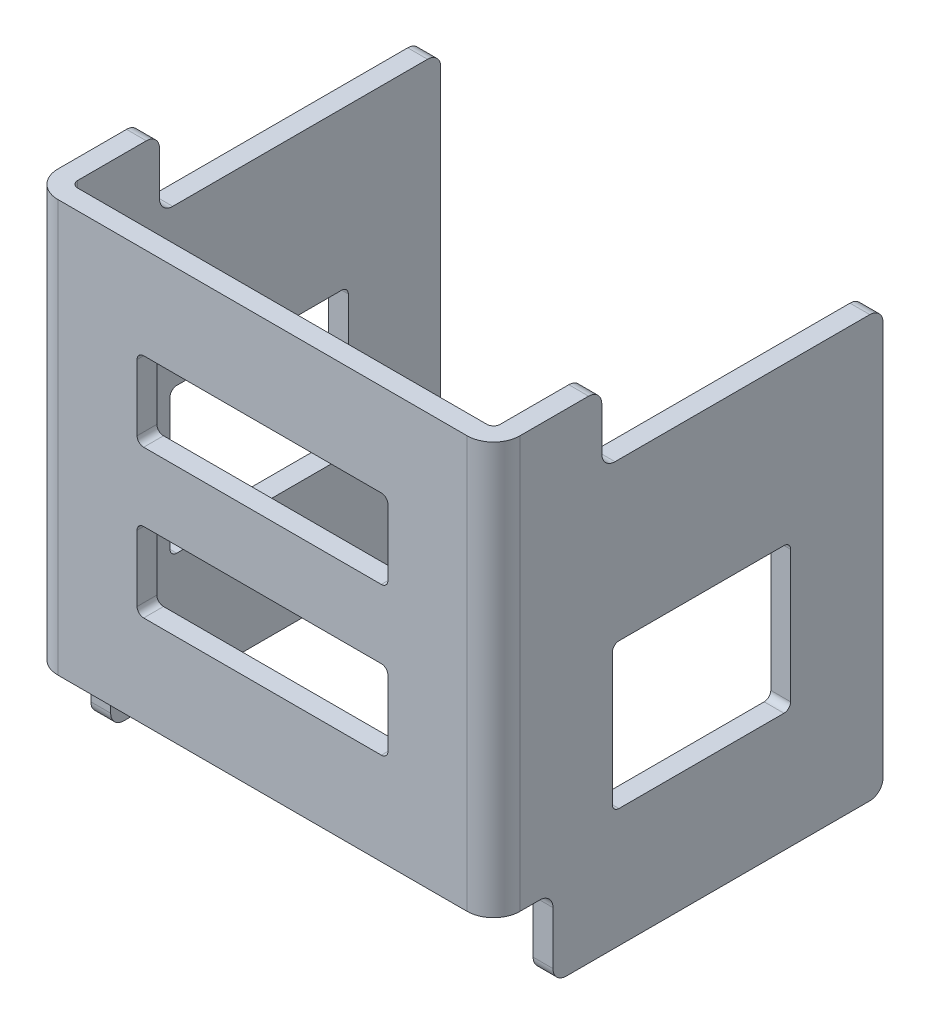
from build123d import *

# Parameters (mm, degrees)
SKETCH1_W           = 37.2
SKETCH1_H           = 29.5
BOSS_EXTRUDE1_DEPTH = 1.5
SKETCH2_W           = 4.5
SKETCH2_H           = 6
CUT_EXTRUDE1_DEPTH  = 2.5
SKETCH3_W           = 1.5
SKETCH3_H           = 31.2
BOSS_EXTRUDE2_DEPTH = 33.5
SKETCH4_W           = 1.5
SKETCH4_H           = 31.2
BOSS_EXTRUDE3_DEPTH = 28
SKETCH5_W           = 1.5
SKETCH5_H           = 25
BOSS_EXTRUDE4_DEPTH = 6
CUT_EXTRUDE2_REACH  = 37
SKETCH6_W           = 21.3
SKETCH6_H           = 5.3
SKETCH7_W           = 21.3
SKETCH7_H           = 5.3
CUT_EXTRUDE3_DEPTH  = 36
FILLET1_R           = 0.5
FILLET2_R           = 2
SKETCH8_W           = 19
SKETCH8_H           = 6
CUT_EXTRUDE4_DEPTH  = 1.5
FILLET3_R           = 0.5
SKETCH9_W           = 13.5
SKETCH9_H           = 11
CUT_EXTRUDE5_DEPTH  = 35
FILLET4_R           = 0.5
FILLET5_R           = 1


with BuildPart() as part:
    # Sketch1 → Boss-Extrude1 (new body)
    with BuildSketch(Plane(origin=(16, 0, 0), x_dir=(0, -1, 0), z_dir=(-1, 0, 0))):
        with Locations((46.1, 3.75)):
            Rectangle(SKETCH1_W, SKETCH1_H)
    extrude(amount=-BOSS_EXTRUDE1_DEPTH)

    # Sketch2 → Cut-Extrude1 (cut, through all)
    with BuildSketch(Plane(origin=(17.5, 0, 0), x_dir=(0, 0, -1), z_dir=(1, 0, 0))):
        with Locations((-16.25, -61.7)):
            Rectangle(SKETCH2_W, SKETCH2_H)
    extrude(amount=-CUT_EXTRUDE1_DEPTH, mode=Mode.SUBTRACT)

    # Sketch3 → Boss-Extrude2 (add)
    with BuildSketch(Plane.ZY.offset(-16)):
        with Locations((17.75, -43.1)):
            Rectangle(SKETCH3_W, SKETCH3_H)
    extrude(amount=BOSS_EXTRUDE2_DEPTH)

    # Sketch4 → Boss-Extrude3 (add)
    with BuildSketch(Plane(origin=(0, 0, 17), x_dir=(-1, 0, 0), z_dir=(0, 0, -1))):
        with Locations((16.75, -43.1)):
            Rectangle(SKETCH4_W, SKETCH4_H)
    extrude(amount=BOSS_EXTRUDE3_DEPTH)

    # Sketch5 → Boss-Extrude4 (add)
    with BuildSketch(Plane.XZ.offset(58.7)):
        with Locations((-16.75, 1.5)):
            Rectangle(SKETCH5_W, SKETCH5_H)
    extrude(amount=BOSS_EXTRUDE4_DEPTH)

    # Sketch6 → Cut-Extrude2 (cut, up to next)
    with BuildSketch(Plane(origin=(17.5, 0, 0), x_dir=(0, 0, -1), z_dir=(1, 0, 0)), mode=Mode.PRIVATE) as cut_extrude2_sk1:
        with Locations((0.35, -30.15)):
            Rectangle(SKETCH6_W, SKETCH6_H)
    cut_extrude2_tool1 = extrude(cut_extrude2_sk1.sketch, amount=-CUT_EXTRUDE2_REACH, mode=Mode.PRIVATE) & part.part
    add(cut_extrude2_tool1.solids().sort_by_distance((17.5, -30.15, -0.35))[0], mode=Mode.SUBTRACT)

    # Sketch7 → Cut-Extrude3 (cut, through all)
    with BuildSketch(Plane.ZY.offset(17.5)):
        with Locations((-0.35, -30.15)):
            Rectangle(SKETCH7_W, SKETCH7_H)
    extrude(amount=-CUT_EXTRUDE3_DEPTH, mode=Mode.SUBTRACT)

    # Fillet1
    fillet1_edges = [part.edges().sort_by_distance(p)[0] for p in [
        (16, -43.1, 17),
        (-16, -43.1, 17),
    ]]
    fillet(fillet1_edges, radius=FILLET1_R)

    # Fillet2
    fillet2_edges = [part.edges().sort_by_distance(p)[0] for p in [
        (17.5, -43.1, 18.5),
        (-17.5, -43.1, 18.5),
    ]]
    fillet(fillet2_edges, radius=FILLET2_R)

    # Sketch8 → Cut-Extrude4 (cut)
    with BuildSketch(Plane.XY.offset(18.5)):
        with Locations((0, -37.5)):
            Rectangle(SKETCH8_W, SKETCH8_H)
        with Locations((0, -48.7)):
            Rectangle(SKETCH8_W, SKETCH8_H)
    extrude(amount=-CUT_EXTRUDE4_DEPTH, mode=Mode.SUBTRACT)

    # Fillet3
    fillet3_edges = [part.edges().sort_by_distance(p)[0] for p in [
        (9.5, -51.7, 17.75),
        (-9.5, -51.7, 17.75),
        (-9.5, -45.7, 17.75),
        (9.5, -45.7, 17.75),
        (-9.5, -40.5, 17.75),
        (-9.5, -34.5, 17.75),
        (9.5, -34.5, 17.75),
        (9.5, -40.5, 17.75),
    ]]
    fillet(fillet3_edges, radius=FILLET3_R)

    # Sketch9 → Cut-Extrude5 (cut)
    with BuildSketch(Plane(origin=(17.5, 0, 0), x_dir=(0, 0, -1), z_dir=(1, 0, 0))):
        with Locations((-2.75, -50.2)):
            Rectangle(SKETCH9_W, SKETCH9_H)
    extrude(amount=-CUT_EXTRUDE5_DEPTH, mode=Mode.SUBTRACT)

    # Fillet4
    fillet4_edges = [part.edges().sort_by_distance(p)[0] for p in [
        (-16.75, -55.7, 9.5),
        (-16.75, -44.7, 9.5),
        (-16.75, -44.7, -4),
        (-16.75, -55.7, -4),
        (16.75, -55.7, 9.5),
        (16.75, -44.7, 9.5),
        (16.75, -44.7, -4),
        (16.75, -55.7, -4),
    ]]
    fillet(fillet4_edges, radius=FILLET4_R)

    # Fillet5
    fillet5_edges = [part.edges().sort_by_distance(p)[0] for p in [
        (16.75, -58.7, 14),
        (16.75, -64.7, 14),
        (-16.75, -58.7, 14),
        (-16.75, -64.7, -11),
        (-16.75, -64.7, 14),
        (16.75, -32.8, -11),
        (16.75, -32.8, 10.3),
        (16.75, -27.5, 10.3),
        (16.75, -64.7, -11),
        (-16.75, -27.5, 10.3),
        (-16.75, -32.8, -11),
        (-16.75, -32.8, 10.3),
    ]]
    fillet(fillet5_edges, radius=FILLET5_R)


solid = part.part
